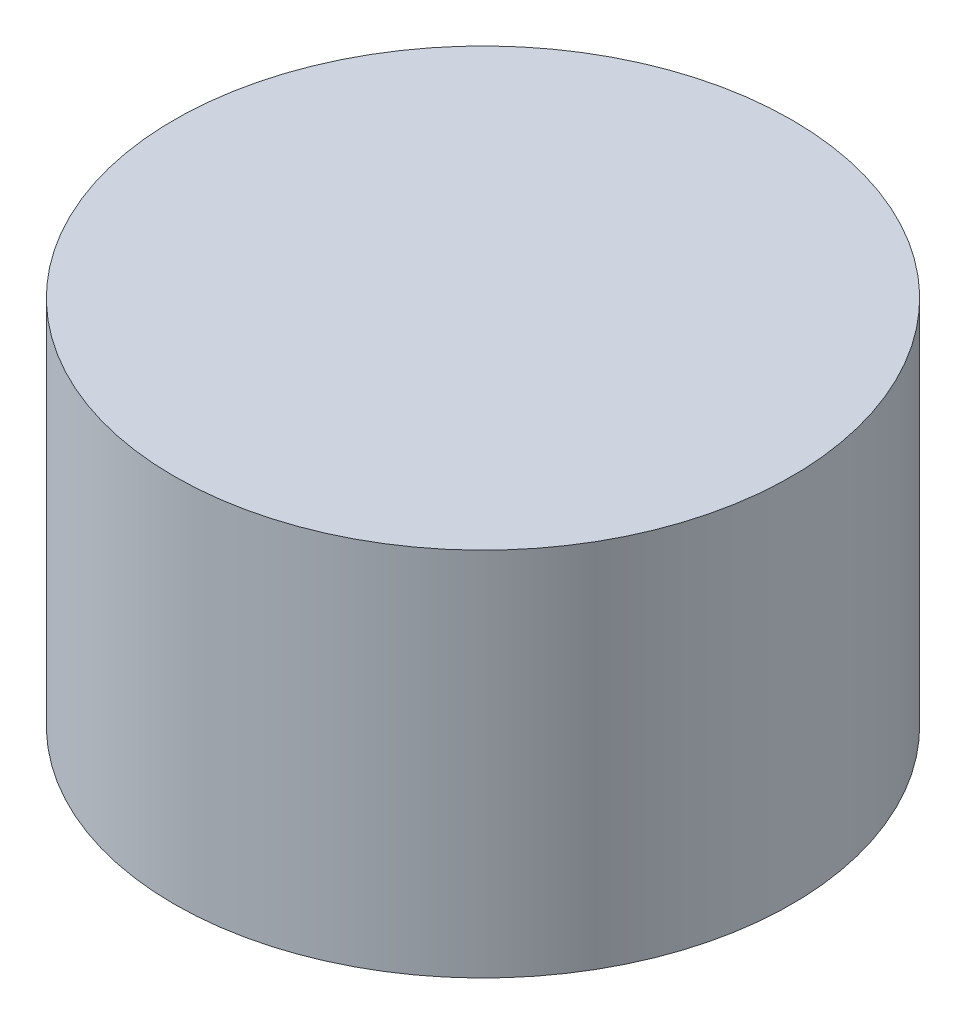
from build123d import *

# Parameters (mm, degrees)
SKETCH1_R           = 5
BOSS_EXTRUDE1_DEPTH = 6


with BuildPart() as part:
    # Sketch1 → Boss-Extrude1 (new body)
    with BuildSketch(Plane(origin=(0, 0, 0), x_dir=(1, 0, 0), z_dir=(0, 1, 0))):
        Circle(SKETCH1_R)
    extrude(amount=BOSS_EXTRUDE1_DEPTH)


solid = part.part
